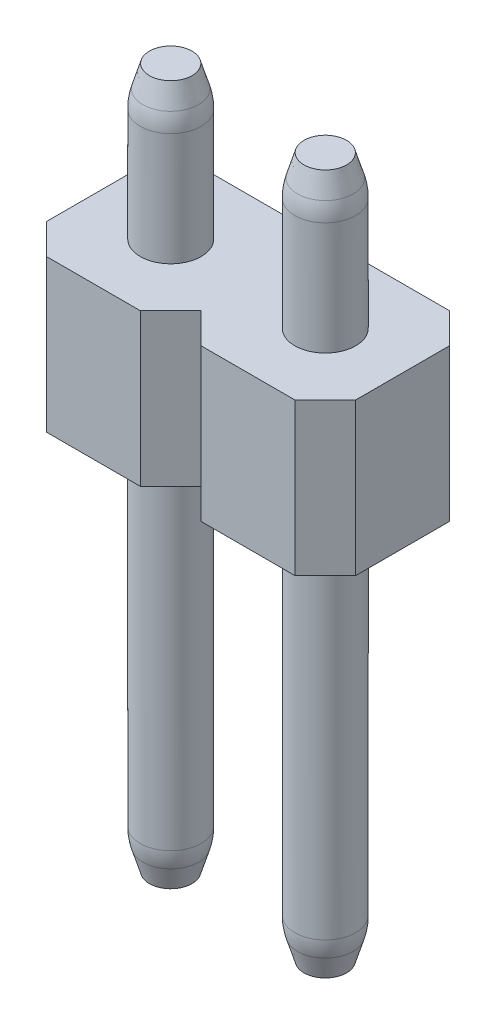
from build123d import *

# Parameters (mm, degrees)
SKETCH1_R               = 0.5
BOSS_EXTRUDE1_DEPTH     = 11.5
BOSS_EXTRUDE1_2_DEPTH   = 11.5
BOSS_EXTRUDE1_3_DEPTH   = 11.5
BOSS_EXTRUDE1_4_DEPTH   = 11.5
BOSS_EXTRUDE1_5_DEPTH   = 11.5
BOSS_EXTRUDE1_6_DEPTH   = 11.5
BOSS_EXTRUDE1_7_DEPTH   = 11.5
BOSS_EXTRUDE1_8_DEPTH   = 11.5
BOSS_EXTRUDE1_9_DEPTH   = 11.5
BOSS_EXTRUDE1_10_DEPTH  = 11.5
BOSS_EXTRUDE1_11_DEPTH  = 11.5
BOSS_EXTRUDE1_12_DEPTH  = 11.5
BOSS_EXTRUDE1_13_DEPTH  = 11.5
BOSS_EXTRUDE1_14_DEPTH  = 11.5
BOSS_EXTRUDE1_15_DEPTH  = 11.5
BOSS_EXTRUDE1_16_DEPTH  = 11.5
BOSS_EXTRUDE2_DEPTH     = 2.5
CHAMFER1_SIZE           = 0.5
CHAMFER1_SIZE2          = 0.15
CHAMFER1_PART_2_SIZE    = 0.5
CHAMFER1_PART_2_SIZE2   = 0.15
CHAMFER1_PART_3_SIZE    = 0.5
CHAMFER1_PART_3_SIZE2   = 0.15
CHAMFER1_PART_4_SIZE    = 0.5
CHAMFER1_PART_4_SIZE2   = 0.15
CHAMFER1_PART_5_SIZE    = 0.5
CHAMFER1_PART_5_SIZE2   = 0.15
CHAMFER1_PART_6_SIZE    = 0.5
CHAMFER1_PART_6_SIZE2   = 0.15
CHAMFER1_PART_7_SIZE    = 0.5
CHAMFER1_PART_7_SIZE2   = 0.15
CHAMFER1_PART_8_SIZE    = 0.5
CHAMFER1_PART_8_SIZE2   = 0.15
CHAMFER1_PART_9_SIZE    = 0.5
CHAMFER1_PART_9_SIZE2   = 0.15
CHAMFER1_PART_10_SIZE   = 0.5
CHAMFER1_PART_10_SIZE2  = 0.15
CHAMFER1_PART_11_SIZE   = 0.5
CHAMFER1_PART_11_SIZE2  = 0.15
CHAMFER1_PART_12_SIZE   = 0.5
CHAMFER1_PART_12_SIZE2  = 0.15
CHAMFER1_PART_13_SIZE   = 0.5
CHAMFER1_PART_13_SIZE2  = 0.15
CHAMFER1_PART_14_SIZE   = 0.5
CHAMFER1_PART_14_SIZE2  = 0.15
CHAMFER1_PART_15_SIZE   = 0.5
CHAMFER1_PART_15_SIZE2  = 0.15
CHAMFER1_PART_16_SIZE   = 0.5
CHAMFER1_PART_16_SIZE2  = 0.15
FILLET1_R               = 1
CHAMFER2_SIZE           = 0.15
CHAMFER2_SIZE2          = 0.5
CHAMFER2_PART_2_SIZE    = 0.15
CHAMFER2_PART_2_SIZE2   = 0.5
CHAMFER2_PART_3_SIZE    = 0.15
CHAMFER2_PART_3_SIZE2   = 0.5
CHAMFER2_PART_4_SIZE    = 0.15
CHAMFER2_PART_4_SIZE2   = 0.5
CHAMFER2_PART_5_SIZE    = 0.15
CHAMFER2_PART_5_SIZE2   = 0.5
CHAMFER2_PART_6_SIZE    = 0.15
CHAMFER2_PART_6_SIZE2   = 0.5
CHAMFER2_PART_7_SIZE    = 0.15
CHAMFER2_PART_7_SIZE2   = 0.5
CHAMFER2_PART_8_SIZE    = 0.15
CHAMFER2_PART_8_SIZE2   = 0.5
CHAMFER2_PART_9_SIZE    = 0.15
CHAMFER2_PART_9_SIZE2   = 0.5
CHAMFER2_PART_10_SIZE   = 0.15
CHAMFER2_PART_10_SIZE2  = 0.5
CHAMFER2_PART_11_SIZE   = 0.15
CHAMFER2_PART_11_SIZE2  = 0.5
CHAMFER2_PART_12_SIZE   = 0.15
CHAMFER2_PART_12_SIZE2  = 0.5
CHAMFER2_PART_13_SIZE   = 0.15
CHAMFER2_PART_13_SIZE2  = 0.5
CHAMFER2_PART_14_SIZE   = 0.15
CHAMFER2_PART_14_SIZE2  = 0.5
CHAMFER2_PART_15_SIZE   = 0.15
CHAMFER2_PART_15_SIZE2  = 0.5
CHAMFER2_PART_16_SIZE   = 0.15
CHAMFER2_PART_16_SIZE2  = 0.5
FILLET2_R               = 1
CUT_EXTRUDE1_DEPTH      = 3.54
CUT_EXTRUDE2_DEPTH      = 3.54
SKETCH5_W               = 12.7
SKETCH5_H               = 11.5
CUT_EXTRUDE3_DEPTH      = 1
CUT_EXTRUDE3_DEPTH_BACK = 3.54


with BuildPart() as part:
    # Sketch1 → Boss-Extrude1 (new body)
    with BuildSketch(Plane(origin=(0, 0, 0), x_dir=(1, 0, 0), z_dir=(0, 1, 0))):
        Circle(SKETCH1_R)
    extrude(amount=BOSS_EXTRUDE1_DEPTH)



with BuildPart() as body_2:
    # Sketch1 → Boss-Extrude1 2 (new body)
    with BuildSketch(Plane(origin=(0, 0, 0), x_dir=(1, 0, 0), z_dir=(0, 1, 0))):
        with Locations((2.54, 0)):
            Circle(SKETCH1_R)
    extrude(amount=BOSS_EXTRUDE1_2_DEPTH)


with BuildPart() as body_3:
    # Sketch1 → Boss-Extrude1 3 (new body)
    with BuildSketch(Plane(origin=(0, 0, 0), x_dir=(1, 0, 0), z_dir=(0, 1, 0))):
        with Locations((5.08, 0)):
            Circle(SKETCH1_R)
    extrude(amount=BOSS_EXTRUDE1_3_DEPTH)


with BuildPart() as body_4:
    # Sketch1 → Boss-Extrude1 4 (new body)
    with BuildSketch(Plane(origin=(0, 0, 0), x_dir=(1, 0, 0), z_dir=(0, 1, 0))):
        with Locations((7.62, 0)):
            Circle(SKETCH1_R)
    extrude(amount=BOSS_EXTRUDE1_4_DEPTH)


with BuildPart() as body_5:
    # Sketch1 → Boss-Extrude1 5 (new body)
    with BuildSketch(Plane(origin=(0, 0, 0), x_dir=(1, 0, 0), z_dir=(0, 1, 0))):
        with Locations((10.16, 0)):
            Circle(SKETCH1_R)
    extrude(amount=BOSS_EXTRUDE1_5_DEPTH)


with BuildPart() as body_6:
    # Sketch1 → Boss-Extrude1 6 (new body)
    with BuildSketch(Plane(origin=(0, 0, 0), x_dir=(1, 0, 0), z_dir=(0, 1, 0))):
        with Locations((12.7, 0)):
            Circle(SKETCH1_R)
    extrude(amount=BOSS_EXTRUDE1_6_DEPTH)


with BuildPart() as body_7:
    # Sketch1 → Boss-Extrude1 7 (new body)
    with BuildSketch(Plane(origin=(0, 0, 0), x_dir=(1, 0, 0), z_dir=(0, 1, 0))):
        with Locations((15.24, 0)):
            Circle(SKETCH1_R)
    extrude(amount=BOSS_EXTRUDE1_7_DEPTH)


with BuildPart() as body_8:
    # Sketch1 → Boss-Extrude1 8 (new body)
    with BuildSketch(Plane(origin=(0, 0, 0), x_dir=(1, 0, 0), z_dir=(0, 1, 0))):
        with Locations((17.78, 0)):
            Circle(SKETCH1_R)
    extrude(amount=BOSS_EXTRUDE1_8_DEPTH)


with BuildPart() as body_9:
    # Sketch1 → Boss-Extrude1 9 (new body)
    with BuildSketch(Plane(origin=(0, 0, 0), x_dir=(1, 0, 0), z_dir=(0, 1, 0))):
        with Locations((20.32, 0)):
            Circle(SKETCH1_R)
    extrude(amount=BOSS_EXTRUDE1_9_DEPTH)


with BuildPart() as body_10:
    # Sketch1 → Boss-Extrude1 10 (new body)
    with BuildSketch(Plane(origin=(0, 0, 0), x_dir=(1, 0, 0), z_dir=(0, 1, 0))):
        with Locations((22.86, 0)):
            Circle(SKETCH1_R)
    extrude(amount=BOSS_EXTRUDE1_10_DEPTH)


with BuildPart() as body_11:
    # Sketch1 → Boss-Extrude1 11 (new body)
    with BuildSketch(Plane(origin=(0, 0, 0), x_dir=(1, 0, 0), z_dir=(0, 1, 0))):
        with Locations((25.4, 0)):
            Circle(SKETCH1_R)
    extrude(amount=BOSS_EXTRUDE1_11_DEPTH)


with BuildPart() as body_12:
    # Sketch1 → Boss-Extrude1 12 (new body)
    with BuildSketch(Plane(origin=(0, 0, 0), x_dir=(1, 0, 0), z_dir=(0, 1, 0))):
        with Locations((27.94, 0)):
            Circle(SKETCH1_R)
    extrude(amount=BOSS_EXTRUDE1_12_DEPTH)


with BuildPart() as body_13:
    # Sketch1 → Boss-Extrude1 13 (new body)
    with BuildSketch(Plane(origin=(0, 0, 0), x_dir=(1, 0, 0), z_dir=(0, 1, 0))):
        with Locations((30.48, 0)):
            Circle(SKETCH1_R)
    extrude(amount=BOSS_EXTRUDE1_13_DEPTH)


with BuildPart() as body_14:
    # Sketch1 → Boss-Extrude1 14 (new body)
    with BuildSketch(Plane(origin=(0, 0, 0), x_dir=(1, 0, 0), z_dir=(0, 1, 0))):
        with Locations((33.02, 0)):
            Circle(SKETCH1_R)
    extrude(amount=BOSS_EXTRUDE1_14_DEPTH)


with BuildPart() as body_15:
    # Sketch1 → Boss-Extrude1 15 (new body)
    with BuildSketch(Plane(origin=(0, 0, 0), x_dir=(1, 0, 0), z_dir=(0, 1, 0))):
        with Locations((35.56, 0)):
            Circle(SKETCH1_R)
    extrude(amount=BOSS_EXTRUDE1_15_DEPTH)


with BuildPart() as body_16:
    # Sketch1 → Boss-Extrude1 16 (new body)
    with BuildSketch(Plane(origin=(0, 0, 0), x_dir=(1, 0, 0), z_dir=(0, 1, 0))):
        with Locations((38.1, 0)):
            Circle(SKETCH1_R)
    extrude(amount=BOSS_EXTRUDE1_16_DEPTH)


with BuildPart() as part_1:
    add(part.part)

    add(body_2.part)  # Boss-Extrude2 merges body 2

    add(body_3.part)  # Boss-Extrude2 merges body 3

    add(body_4.part)  # Boss-Extrude2 merges body 4

    add(body_5.part)  # Boss-Extrude2 merges body 5

    add(body_6.part)  # Boss-Extrude2 merges body 6

    add(body_7.part)  # Boss-Extrude2 merges body 7

    add(body_8.part)  # Boss-Extrude2 merges body 8

    add(body_9.part)  # Boss-Extrude2 merges body 9

    add(body_10.part)  # Boss-Extrude2 merges body 10

    add(body_11.part)  # Boss-Extrude2 merges body 11

    add(body_12.part)  # Boss-Extrude2 merges body 12

    add(body_13.part)  # Boss-Extrude2 merges body 13

    add(body_14.part)  # Boss-Extrude2 merges body 14

    add(body_15.part)  # Boss-Extrude2 merges body 15

    add(body_16.part)  # Boss-Extrude2 merges body 16
    # Sketch2 → Boss-Extrude2 (add)
    with BuildSketch(Plane(origin=(0, 6.5, 0), x_dir=(1, 0, 0), z_dir=(0, 1, 0))):
        Polygon((-1.27, 0.77), (-0.77, 1.27), (0.77, 1.27), (1.27, 0.77), (1.77, 1.27), (3.31, 1.27), (3.81, 0.77), (4.31, 1.27), (5.85, 1.27), (6.35, 0.77), (6.85, 1.27), (8.39, 1.27), (8.89, 0.77), (9.39, 1.27), (10.93, 1.27), (11.43, 0.77), (11.93, 1.27), (13.47, 1.27), (13.97, 0.77), (14.47, 1.27), (16.01, 1.27), (16.51, 0.77), (17.01, 1.27), (18.55, 1.27), (19.05, 0.77), (19.55, 1.27), (21.09, 1.27), (21.59, 0.77), (22.09, 1.27), (23.63, 1.27), (24.13, 0.77), (24.63, 1.27), (26.17, 1.27), (26.67, 0.77), (27.17, 1.27), (28.71, 1.27), (29.21, 0.77), (29.71, 1.27), (31.25, 1.27), (31.75, 0.77), (32.25, 1.27), (33.79, 1.27), (34.29, 0.77), (34.79, 1.27), (36.33, 1.27), (36.83, 0.77), (37.33, 1.27), (38.87, 1.27), (39.37, 0.77), (39.37, -0.77), (38.87, -1.27), (37.33, -1.27), (36.83, -0.77), (36.33, -1.27), (34.79, -1.27), (34.29, -0.77), (33.79, -1.27), (32.25, -1.27), (31.75, -0.77), (31.25, -1.27), (29.71, -1.27), (29.21, -0.77), (28.71, -1.27), (27.17, -1.27), (26.67, -0.77), (26.17, -1.27), (24.63, -1.27), (24.13, -0.77), (23.63, -1.27), (22.09, -1.27), (21.59, -0.77), (21.09, -1.27), (19.55, -1.27), (19.05, -0.77), (18.55, -1.27), (17.01, -1.27), (16.51, -0.77), (16.01, -1.27), (14.47, -1.27), (13.97, -0.77), (13.47, -1.27), (11.93, -1.27), (11.43, -0.77), (10.93, -1.27), (9.39, -1.27), (8.89, -0.77), (8.39, -1.27), (6.85, -1.27), (6.35, -0.77), (5.85, -1.27), (4.31, -1.27), (3.81, -0.77), (3.31, -1.27), (1.77, -1.27), (1.27, -0.77), (0.77, -1.27), (-0.77, -1.27), (-1.27, -0.77), align=None)
    extrude(amount=BOSS_EXTRUDE2_DEPTH)

    # Chamfer1
    chamfer1_edges = [part_1.edges().sort_by_distance(p)[0] for p in [
        (2.04, 11.5, 0),
    ]]
    chamfer1_side = [part_1.faces().sort_by_distance(p)[0] for p in [
        (2.04, 10.25, 0),
    ]]
    chamfer(chamfer1_edges, length=CHAMFER1_SIZE, length2=CHAMFER1_SIZE2, reference=chamfer1_side[0])

    # Chamfer1 part 2
    chamfer1_part_2_edges = [part_1.edges().sort_by_distance(p)[0] for p in [
        (4.58, 11.5, 0),
    ]]
    chamfer1_part_2_side = [part_1.faces().sort_by_distance(p)[0] for p in [
        (4.58, 10.25, 0),
    ]]
    chamfer(chamfer1_part_2_edges, length=CHAMFER1_PART_2_SIZE, length2=CHAMFER1_PART_2_SIZE2, reference=chamfer1_part_2_side[0])

    # Chamfer1 part 3
    chamfer1_part_3_edges = [part_1.edges().sort_by_distance(p)[0] for p in [
        (7.12, 11.5, 0),
    ]]
    chamfer1_part_3_side = [part_1.faces().sort_by_distance(p)[0] for p in [
        (7.12, 10.25, 0),
    ]]
    chamfer(chamfer1_part_3_edges, length=CHAMFER1_PART_3_SIZE, length2=CHAMFER1_PART_3_SIZE2, reference=chamfer1_part_3_side[0])

    # Chamfer1 part 4
    chamfer1_part_4_edges = [part_1.edges().sort_by_distance(p)[0] for p in [
        (9.66, 11.5, 0),
    ]]
    chamfer1_part_4_side = [part_1.faces().sort_by_distance(p)[0] for p in [
        (9.66, 10.25, 0),
    ]]
    chamfer(chamfer1_part_4_edges, length=CHAMFER1_PART_4_SIZE, length2=CHAMFER1_PART_4_SIZE2, reference=chamfer1_part_4_side[0])

    # Chamfer1 part 5
    chamfer1_part_5_edges = [part_1.edges().sort_by_distance(p)[0] for p in [
        (12.2, 11.5, 0),
    ]]
    chamfer1_part_5_side = [part_1.faces().sort_by_distance(p)[0] for p in [
        (12.2, 10.25, 0),
    ]]
    chamfer(chamfer1_part_5_edges, length=CHAMFER1_PART_5_SIZE, length2=CHAMFER1_PART_5_SIZE2, reference=chamfer1_part_5_side[0])

    # Chamfer1 part 6
    chamfer1_part_6_edges = [part_1.edges().sort_by_distance(p)[0] for p in [
        (14.74, 11.5, 0),
    ]]
    chamfer1_part_6_side = [part_1.faces().sort_by_distance(p)[0] for p in [
        (14.74, 10.25, 0),
    ]]
    chamfer(chamfer1_part_6_edges, length=CHAMFER1_PART_6_SIZE, length2=CHAMFER1_PART_6_SIZE2, reference=chamfer1_part_6_side[0])

    # Chamfer1 part 7
    chamfer1_part_7_edges = [part_1.edges().sort_by_distance(p)[0] for p in [
        (17.28, 11.5, 0),
    ]]
    chamfer1_part_7_side = [part_1.faces().sort_by_distance(p)[0] for p in [
        (17.28, 10.25, 0),
    ]]
    chamfer(chamfer1_part_7_edges, length=CHAMFER1_PART_7_SIZE, length2=CHAMFER1_PART_7_SIZE2, reference=chamfer1_part_7_side[0])

    # Chamfer1 part 8
    chamfer1_part_8_edges = [part_1.edges().sort_by_distance(p)[0] for p in [
        (19.82, 11.5, 0),
    ]]
    chamfer1_part_8_side = [part_1.faces().sort_by_distance(p)[0] for p in [
        (19.82, 10.25, 0),
    ]]
    chamfer(chamfer1_part_8_edges, length=CHAMFER1_PART_8_SIZE, length2=CHAMFER1_PART_8_SIZE2, reference=chamfer1_part_8_side[0])

    # Chamfer1 part 9
    chamfer1_part_9_edges = [part_1.edges().sort_by_distance(p)[0] for p in [
        (22.36, 11.5, 0),
    ]]
    chamfer1_part_9_side = [part_1.faces().sort_by_distance(p)[0] for p in [
        (22.36, 10.25, 0),
    ]]
    chamfer(chamfer1_part_9_edges, length=CHAMFER1_PART_9_SIZE, length2=CHAMFER1_PART_9_SIZE2, reference=chamfer1_part_9_side[0])

    # Chamfer1 part 10
    chamfer1_part_10_edges = [part_1.edges().sort_by_distance(p)[0] for p in [
        (24.9, 11.5, 0),
    ]]
    chamfer1_part_10_side = [part_1.faces().sort_by_distance(p)[0] for p in [
        (24.9, 10.25, 0),
    ]]
    chamfer(chamfer1_part_10_edges, length=CHAMFER1_PART_10_SIZE, length2=CHAMFER1_PART_10_SIZE2, reference=chamfer1_part_10_side[0])

    # Chamfer1 part 11
    chamfer1_part_11_edges = [part_1.edges().sort_by_distance(p)[0] for p in [
        (27.44, 11.5, 0),
    ]]
    chamfer1_part_11_side = [part_1.faces().sort_by_distance(p)[0] for p in [
        (27.44, 10.25, 0),
    ]]
    chamfer(chamfer1_part_11_edges, length=CHAMFER1_PART_11_SIZE, length2=CHAMFER1_PART_11_SIZE2, reference=chamfer1_part_11_side[0])

    # Chamfer1 part 12
    chamfer1_part_12_edges = [part_1.edges().sort_by_distance(p)[0] for p in [
        (29.98, 11.5, 0),
    ]]
    chamfer1_part_12_side = [part_1.faces().sort_by_distance(p)[0] for p in [
        (29.98, 10.25, 0),
    ]]
    chamfer(chamfer1_part_12_edges, length=CHAMFER1_PART_12_SIZE, length2=CHAMFER1_PART_12_SIZE2, reference=chamfer1_part_12_side[0])

    # Chamfer1 part 13
    chamfer1_part_13_edges = [part_1.edges().sort_by_distance(p)[0] for p in [
        (32.52, 11.5, 0),
    ]]
    chamfer1_part_13_side = [part_1.faces().sort_by_distance(p)[0] for p in [
        (32.52, 10.25, 0),
    ]]
    chamfer(chamfer1_part_13_edges, length=CHAMFER1_PART_13_SIZE, length2=CHAMFER1_PART_13_SIZE2, reference=chamfer1_part_13_side[0])

    # Chamfer1 part 14
    chamfer1_part_14_edges = [part_1.edges().sort_by_distance(p)[0] for p in [
        (35.06, 11.5, 0),
    ]]
    chamfer1_part_14_side = [part_1.faces().sort_by_distance(p)[0] for p in [
        (35.06, 10.25, 0),
    ]]
    chamfer(chamfer1_part_14_edges, length=CHAMFER1_PART_14_SIZE, length2=CHAMFER1_PART_14_SIZE2, reference=chamfer1_part_14_side[0])

    # Chamfer1 part 15
    chamfer1_part_15_edges = [part_1.edges().sort_by_distance(p)[0] for p in [
        (37.6, 11.5, 0),
    ]]
    chamfer1_part_15_side = [part_1.faces().sort_by_distance(p)[0] for p in [
        (37.6, 10.25, 0),
    ]]
    chamfer(chamfer1_part_15_edges, length=CHAMFER1_PART_15_SIZE, length2=CHAMFER1_PART_15_SIZE2, reference=chamfer1_part_15_side[0])

    # Chamfer1 part 16
    chamfer1_part_16_edges = [part_1.edges().sort_by_distance(p)[0] for p in [
        (-0.5, 11.5, 0),
    ]]
    chamfer1_part_16_side = [part_1.faces().sort_by_distance(p)[0] for p in [
        (-0.5, 10.25, 0),
    ]]
    chamfer(chamfer1_part_16_edges, length=CHAMFER1_PART_16_SIZE, length2=CHAMFER1_PART_16_SIZE2, reference=chamfer1_part_16_side[0])

    # Fillet1
    fillet1_edges = [part_1.edges().sort_by_distance(p)[0] for p in [
        (37.6, 11, 0),
        (35.06, 11, 0),
        (32.52, 11, 0),
        (29.98, 11, 0),
        (27.44, 11, 0),
        (24.9, 11, 0),
        (22.36, 11, 0),
        (19.82, 11, 0),
        (17.28, 11, 0),
        (14.74, 11, 0),
        (12.2, 11, 0),
        (9.66, 11, 0),
        (7.12, 11, 0),
        (4.58, 11, 0),
        (2.04, 11, 0),
        (-0.5, 11, 0),
    ]]
    fillet(fillet1_edges, radius=FILLET1_R)

    # Chamfer2
    chamfer2_edges = [part_1.edges().sort_by_distance(p)[0] for p in [
        (-0.5, 0, 0),
    ]]
    chamfer2_side = [part_1.faces().sort_by_distance(p)[0] for p in [
        (0, 0, 0),
    ]]
    chamfer(chamfer2_edges, length=CHAMFER2_SIZE, length2=CHAMFER2_SIZE2, reference=chamfer2_side[0])

    # Chamfer2 part 2
    chamfer2_part_2_edges = [part_1.edges().sort_by_distance(p)[0] for p in [
        (2.04, 0, 0),
    ]]
    chamfer2_part_2_side = [part_1.faces().sort_by_distance(p)[0] for p in [
        (2.54, 0, 0),
    ]]
    chamfer(chamfer2_part_2_edges, length=CHAMFER2_PART_2_SIZE, length2=CHAMFER2_PART_2_SIZE2, reference=chamfer2_part_2_side[0])

    # Chamfer2 part 3
    chamfer2_part_3_edges = [part_1.edges().sort_by_distance(p)[0] for p in [
        (4.58, 0, 0),
    ]]
    chamfer2_part_3_side = [part_1.faces().sort_by_distance(p)[0] for p in [
        (5.08, 0, 0),
    ]]
    chamfer(chamfer2_part_3_edges, length=CHAMFER2_PART_3_SIZE, length2=CHAMFER2_PART_3_SIZE2, reference=chamfer2_part_3_side[0])

    # Chamfer2 part 4
    chamfer2_part_4_edges = [part_1.edges().sort_by_distance(p)[0] for p in [
        (7.12, 0, 0),
    ]]
    chamfer2_part_4_side = [part_1.faces().sort_by_distance(p)[0] for p in [
        (7.62, 0, 0),
    ]]
    chamfer(chamfer2_part_4_edges, length=CHAMFER2_PART_4_SIZE, length2=CHAMFER2_PART_4_SIZE2, reference=chamfer2_part_4_side[0])

    # Chamfer2 part 5
    chamfer2_part_5_edges = [part_1.edges().sort_by_distance(p)[0] for p in [
        (9.66, 0, 0),
    ]]
    chamfer2_part_5_side = [part_1.faces().sort_by_distance(p)[0] for p in [
        (10.16, 0, 0),
    ]]
    chamfer(chamfer2_part_5_edges, length=CHAMFER2_PART_5_SIZE, length2=CHAMFER2_PART_5_SIZE2, reference=chamfer2_part_5_side[0])

    # Chamfer2 part 6
    chamfer2_part_6_edges = [part_1.edges().sort_by_distance(p)[0] for p in [
        (12.2, 0, 0),
    ]]
    chamfer2_part_6_side = [part_1.faces().sort_by_distance(p)[0] for p in [
        (12.7, 0, 0),
    ]]
    chamfer(chamfer2_part_6_edges, length=CHAMFER2_PART_6_SIZE, length2=CHAMFER2_PART_6_SIZE2, reference=chamfer2_part_6_side[0])

    # Chamfer2 part 7
    chamfer2_part_7_edges = [part_1.edges().sort_by_distance(p)[0] for p in [
        (14.74, 0, 0),
    ]]
    chamfer2_part_7_side = [part_1.faces().sort_by_distance(p)[0] for p in [
        (15.24, 0, 0),
    ]]
    chamfer(chamfer2_part_7_edges, length=CHAMFER2_PART_7_SIZE, length2=CHAMFER2_PART_7_SIZE2, reference=chamfer2_part_7_side[0])

    # Chamfer2 part 8
    chamfer2_part_8_edges = [part_1.edges().sort_by_distance(p)[0] for p in [
        (17.28, 0, 0),
    ]]
    chamfer2_part_8_side = [part_1.faces().sort_by_distance(p)[0] for p in [
        (17.78, 0, 0),
    ]]
    chamfer(chamfer2_part_8_edges, length=CHAMFER2_PART_8_SIZE, length2=CHAMFER2_PART_8_SIZE2, reference=chamfer2_part_8_side[0])

    # Chamfer2 part 9
    chamfer2_part_9_edges = [part_1.edges().sort_by_distance(p)[0] for p in [
        (19.82, 0, 0),
    ]]
    chamfer2_part_9_side = [part_1.faces().sort_by_distance(p)[0] for p in [
        (20.32, 0, 0),
    ]]
    chamfer(chamfer2_part_9_edges, length=CHAMFER2_PART_9_SIZE, length2=CHAMFER2_PART_9_SIZE2, reference=chamfer2_part_9_side[0])

    # Chamfer2 part 10
    chamfer2_part_10_edges = [part_1.edges().sort_by_distance(p)[0] for p in [
        (22.36, 0, 0),
    ]]
    chamfer2_part_10_side = [part_1.faces().sort_by_distance(p)[0] for p in [
        (22.86, 0, 0),
    ]]
    chamfer(chamfer2_part_10_edges, length=CHAMFER2_PART_10_SIZE, length2=CHAMFER2_PART_10_SIZE2, reference=chamfer2_part_10_side[0])

    # Chamfer2 part 11
    chamfer2_part_11_edges = [part_1.edges().sort_by_distance(p)[0] for p in [
        (24.9, 0, 0),
    ]]
    chamfer2_part_11_side = [part_1.faces().sort_by_distance(p)[0] for p in [
        (25.4, 0, 0),
    ]]
    chamfer(chamfer2_part_11_edges, length=CHAMFER2_PART_11_SIZE, length2=CHAMFER2_PART_11_SIZE2, reference=chamfer2_part_11_side[0])

    # Chamfer2 part 12
    chamfer2_part_12_edges = [part_1.edges().sort_by_distance(p)[0] for p in [
        (27.44, 0, 0),
    ]]
    chamfer2_part_12_side = [part_1.faces().sort_by_distance(p)[0] for p in [
        (27.94, 0, 0),
    ]]
    chamfer(chamfer2_part_12_edges, length=CHAMFER2_PART_12_SIZE, length2=CHAMFER2_PART_12_SIZE2, reference=chamfer2_part_12_side[0])

    # Chamfer2 part 13
    chamfer2_part_13_edges = [part_1.edges().sort_by_distance(p)[0] for p in [
        (29.98, 0, 0),
    ]]
    chamfer2_part_13_side = [part_1.faces().sort_by_distance(p)[0] for p in [
        (30.48, 0, 0),
    ]]
    chamfer(chamfer2_part_13_edges, length=CHAMFER2_PART_13_SIZE, length2=CHAMFER2_PART_13_SIZE2, reference=chamfer2_part_13_side[0])

    # Chamfer2 part 14
    chamfer2_part_14_edges = [part_1.edges().sort_by_distance(p)[0] for p in [
        (32.52, 0, 0),
    ]]
    chamfer2_part_14_side = [part_1.faces().sort_by_distance(p)[0] for p in [
        (33.02, 0, 0),
    ]]
    chamfer(chamfer2_part_14_edges, length=CHAMFER2_PART_14_SIZE, length2=CHAMFER2_PART_14_SIZE2, reference=chamfer2_part_14_side[0])

    # Chamfer2 part 15
    chamfer2_part_15_edges = [part_1.edges().sort_by_distance(p)[0] for p in [
        (35.06, 0, 0),
    ]]
    chamfer2_part_15_side = [part_1.faces().sort_by_distance(p)[0] for p in [
        (35.56, 0, 0),
    ]]
    chamfer(chamfer2_part_15_edges, length=CHAMFER2_PART_15_SIZE, length2=CHAMFER2_PART_15_SIZE2, reference=chamfer2_part_15_side[0])

    # Chamfer2 part 16
    chamfer2_part_16_edges = [part_1.edges().sort_by_distance(p)[0] for p in [
        (37.6, 0, 0),
    ]]
    chamfer2_part_16_side = [part_1.faces().sort_by_distance(p)[0] for p in [
        (38.1, 0, 0),
    ]]
    chamfer(chamfer2_part_16_edges, length=CHAMFER2_PART_16_SIZE, length2=CHAMFER2_PART_16_SIZE2, reference=chamfer2_part_16_side[0])

    # Fillet2
    fillet2_edges = [part_1.edges().sort_by_distance(p)[0] for p in [
        (9.66, 0.5, 0),
        (17.28, 0.5, 0),
        (22.36, 0.5, 0),
        (27.44, 0.5, 0),
        (29.98, 0.5, 0),
        (-0.5, 0.5, 0),
        (2.04, 0.5, 0),
        (4.58, 0.5, 0),
        (7.12, 0.5, 0),
        (12.2, 0.5, 0),
        (14.74, 0.5, 0),
        (19.82, 0.5, 0),
        (24.9, 0.5, 0),
        (32.52, 0.5, 0),
        (35.06, 0.5, 0),
        (37.6, 0.5, 0),
    ]]
    fillet(fillet2_edges, radius=FILLET2_R)

    # Sketch3 → Cut-Extrude1 (cut, through all)
    with BuildSketch(Plane.XY.offset(1.27)):
        Polygon((29.21, 9), (29.21, 6.5), (29.21, -0.904576426), (41.732415353, -0.904576426), (41.732415353, 12.006276544), (29.21, 12.006276544), align=None)
    extrude(amount=-CUT_EXTRUDE1_DEPTH, mode=Mode.SUBTRACT)

    # Sketch4 → Cut-Extrude2 (cut, through all)
    with BuildSketch(Plane.XY.offset(1.27)):
        Polygon((16.51, 9), (16.51, 6.5), (16.51, -1.163081692), (30.596050739, -1.163081692), (30.596050739, 12.130577479), (16.51, 12.130577479), align=None)
    extrude(amount=-CUT_EXTRUDE2_DEPTH, mode=Mode.SUBTRACT)

    # Sketch5 → Cut-Extrude3 (cut, two sides)
    with BuildSketch(Plane.XY.offset(1.27)) as cut_extrude3_sk:
        with Locations((10.16, 5.75)):
            Rectangle(SKETCH5_W, SKETCH5_H)
    extrude(amount=CUT_EXTRUDE3_DEPTH, mode=Mode.SUBTRACT)
    extrude(cut_extrude3_sk.sketch, amount=-CUT_EXTRUDE3_DEPTH_BACK, mode=Mode.SUBTRACT)


solid = part_1.part
